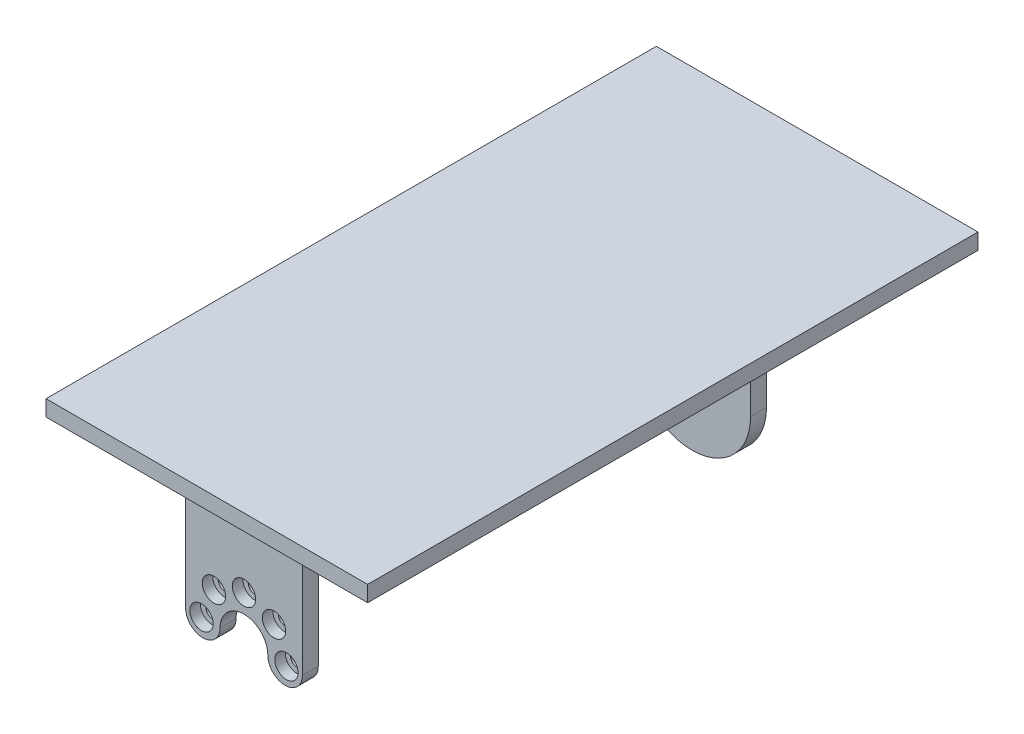
from build123d import *

# Parameters (mm, degrees)
RESSALTO_EXTRUS_O1_DEPTH                            = 3
ESBO_O2_W                                           = 60.6
ESBO_O2_H                                           = 115
RESSALTO_EXTRUS_O2_DEPTH                            = 3
RESSALTO_EXTRUS_O3_DEPTH                            = 3
REBAIXO_PARA_SHCS_M21_D                             = 2.4
REBAIXO_PARA_SHCS_M21_DEPTH                         = 3
REBAIXO_PARA_SHCS_M21_CBORE_D                       = 4.4
REBAIXO_PARA_SHCS_M21_CBORE_DEPTH                   = 2
PADR_OCIRCULAR1_COUNT                               = 5
PADR_OCIRCULAR1_ANGLE                               = 180
NERVURA1_REACH                                      = 114.814
ESBO_O6_WALL_W                                      = 237.528305154
ESBO_O6_WALL_H                                      = 15
CORTE_EXTRUS_O1_REACH                               = 117.612
ESBO_O7_W                                           = 10
ESBO_O7_H                                           = 7
NERVURA7_REACH                                      = 114.814
ESBO_O8_WALL_W                                      = 237.528305154
ESBO_O8_WALL_H                                      = 15
CORTE_EXTRUS_O2_REACH                               = 114.814
ESBO_O9_W                                           = 10
ESBO_O9_H                                           = 7
PADR_O_LINEAR1_COUNT                                = 2
PADR_O_LINEAR1_PITCH                                = 84.45
ESBO_O10_R                                          = 2.75
RESSALTO_EXTRUS_O4_DEPTH                            = 0.6
REBAIXO_PARA_PARAFUSO_COM_CABE_A_PANELA_D           = 3.4
REBAIXO_PARA_PARAFUSO_COM_CABE_A_PANELA_CBORE_D     = 7
REBAIXO_PARA_PARAFUSO_COM_CABE_A_PANELA_CBORE_DEPTH = 1.5


with BuildPart() as part:
    # Esboço1 → Ressalto-extrusão1 (new body)
    with BuildSketch(Plane.XY):
        with BuildLine():
            Line((11, 0), (11, 25))
            Line((11, 25), (-11, 25))
            Line((-11, 25), (-11, 0))
            ThreePointArc((-11, 0), (-7.75, -3.25), (-4.5, 0))
            ThreePointArc((-4.5, 0), (0, 4.5), (4.5, 0))
            ThreePointArc((4.5, 0), (7.75, -3.25), (11, 0))
        make_face()
    extrude(amount=RESSALTO_EXTRUS_O1_DEPTH)

    # Esboço2 → Ressalto-extrusão2 (add)
    with BuildSketch(Plane(origin=(0, 25, 0), x_dir=(1, 0, 0), z_dir=(0, 1, 0))):
        with Locations((0, 47.5)):
            Rectangle(ESBO_O2_W, ESBO_O2_H)
    extrude(amount=RESSALTO_EXTRUS_O2_DEPTH)

    # Esboço3 → Ressalto-extrusão3 (add)
    with BuildSketch(Plane(origin=(0, 0, -81.45), x_dir=(-1, 0, 0), z_dir=(0, 0, -1))):
        with BuildLine():
            Line((-11, 0), (-11, 25))
            Line((-11, 25), (11, 25))
            Line((11, 25), (11, 0))
            ThreePointArc((11, 0), (0, -11), (-11, 0))
        make_face()
    extrude(amount=RESSALTO_EXTRUS_O3_DEPTH)

    # Rebaixo para SHCS M21
    with Locations(Plane.XY.offset(3)):
        with Locations((8, 0)):
            rebaixo_para_shcs_m21 = CounterBoreHole(REBAIXO_PARA_SHCS_M21_D / 2, REBAIXO_PARA_SHCS_M21_CBORE_D / 2, REBAIXO_PARA_SHCS_M21_CBORE_DEPTH, depth=REBAIXO_PARA_SHCS_M21_DEPTH)

    # PadrãoCircular1: Rebaixo para SHCS M21 ×5 about axis
    padr_ocircular1_axis = Axis((0, 0, 0), (0, 0, 1))
    for i in range(1, PADR_OCIRCULAR1_COUNT):
        add(rebaixo_para_shcs_m21.rotate(padr_ocircular1_axis, i * PADR_OCIRCULAR1_ANGLE / (PADR_OCIRCULAR1_COUNT - 1)), mode=Mode.SUBTRACT)

    # Esboço6 wall → Nervura1 (add, up to next)
    with BuildSketch(Plane(origin=(0, 21.5, 6.5), x_dir=(0, 0.707106781187, 0.707106781187), z_dir=(0, -0.707106781187, 0.707106781187)), mode=Mode.PRIVATE) as nervura1_sk1:
        Rectangle(ESBO_O6_WALL_W, ESBO_O6_WALL_H)
    nervura1_tool1 = extrude(nervura1_sk1.sketch, amount=-NERVURA1_REACH, mode=Mode.PRIVATE) - part.part
    nervura1 = nervura1_tool1.solids().sort_by_distance((0, 21.5, 6.5))[0]
    add(nervura1)

    # Corte-extrusão1: up to this face of the body (flat: up to its plane)
    corte_extrus_o1_end = Plane(part.part.faces().sort_by_distance((0, 21.5, 6.5))[0])
    # Esboço7 → Corte-extrusão1 (cut, up to the picked face)
    with BuildSketch(Plane.XY.offset(3), mode=Mode.PRIVATE) as corte_extrus_o1_sk1:
        with Locations((0, 21.5)):
            Rectangle(ESBO_O7_W, ESBO_O7_H)
    corte_extrus_o1_tool1 = split(extrude(corte_extrus_o1_sk1.sketch, amount=CORTE_EXTRUS_O1_REACH, mode=Mode.PRIVATE), bisect_by=corte_extrus_o1_end, keep=Keep.BOTH, mode=Mode.PRIVATE)
    corte_extrus_o1 = corte_extrus_o1_tool1.solids().sort_by(Axis((0, 21.5, 3), (0, 0, 1)))[0]
    add(corte_extrus_o1, mode=Mode.SUBTRACT)

    # Esboço8 wall → Nervura7 (add, up to next)
    with BuildSketch(Plane(origin=(0, 21.5, -3.5), x_dir=(0, 0.707106781187, -0.707106781187), z_dir=(0, 0.707106781187, 0.707106781187)), mode=Mode.PRIVATE) as nervura7_sk1:
        Rectangle(ESBO_O8_WALL_W, ESBO_O8_WALL_H)
    nervura7_tool1 = extrude(nervura7_sk1.sketch, amount=NERVURA7_REACH, mode=Mode.PRIVATE) - part.part
    nervura7 = nervura7_tool1.solids().sort_by_distance((0, 21.5, -3.5))[0]
    add(nervura7)

    # Corte-extrusão2: up to this face of the body (flat: up to its plane)
    corte_extrus_o2_end = Plane(part.part.faces().sort_by_distance((0, 21.5, -3.5))[0])
    # Esboço9 → Corte-extrusão2 (cut, up to the picked face)
    with BuildSketch(Plane(origin=(0, 0, 0), x_dir=(-1, 0, 0), z_dir=(0, 0, -1)), mode=Mode.PRIVATE) as corte_extrus_o2_sk1:
        with Locations((0, 21.5)):
            Rectangle(ESBO_O9_W, ESBO_O9_H)
    corte_extrus_o2_tool1 = split(extrude(corte_extrus_o2_sk1.sketch, amount=CORTE_EXTRUS_O2_REACH, mode=Mode.PRIVATE), bisect_by=corte_extrus_o2_end, keep=Keep.BOTH, mode=Mode.PRIVATE)
    corte_extrus_o2 = corte_extrus_o2_tool1.solids().sort_by(Axis((0, 21.5, 0), (0, 0, -1)))[0]
    add(corte_extrus_o2, mode=Mode.SUBTRACT)

    # Padrão linear1: Nervura1, Corte-extrusão1, Nervura7, Corte-extrusão2 ×2
    with Locations(*[(0, 0, -i * PADR_O_LINEAR1_PITCH) for i in range(1, PADR_O_LINEAR1_COUNT)]):
        add(nervura1)
        add(corte_extrus_o1, mode=Mode.SUBTRACT)
        add(nervura7)
        add(corte_extrus_o2, mode=Mode.SUBTRACT)

    # Esboço10 → Ressalto-extrusão4 (add)
    with BuildSketch(Plane.XY.offset(-81.45)):
        with Locations(Location((0, 0, 0), (0, 0, 180))):
            Circle(ESBO_O10_R)
    extrude(amount=RESSALTO_EXTRUS_O4_DEPTH)

    # Rebaixo para parafuso com cabeça panela de M31 (through all)
    with Locations(Plane(origin=(0, 0, -84.45), x_dir=(-1, 0, 0), z_dir=(0, 0, -1))):
        with Locations((0, 0)):
            CounterBoreHole(REBAIXO_PARA_PARAFUSO_COM_CABE_A_PANELA_D / 2, REBAIXO_PARA_PARAFUSO_COM_CABE_A_PANELA_CBORE_D / 2, REBAIXO_PARA_PARAFUSO_COM_CABE_A_PANELA_CBORE_DEPTH)


solid = part.part
